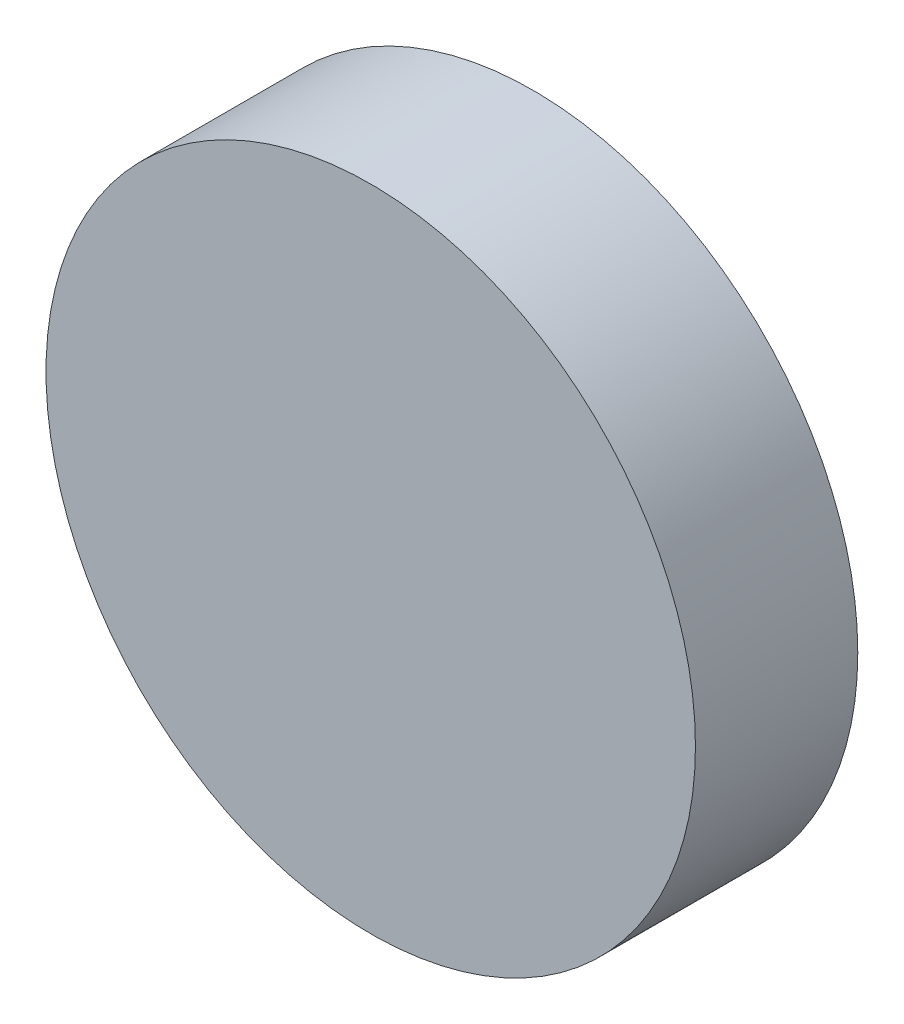
from build123d import *

# Parameters (mm, degrees)
SKETCH1_R           = 4
BOSS_EXTRUDE1_DEPTH = 2


with BuildPart() as part:
    # Sketch1 → Boss-Extrude1 (new body)
    with BuildSketch(Plane.XY):
        Circle(SKETCH1_R)
    extrude(amount=BOSS_EXTRUDE1_DEPTH)


solid = part.part
